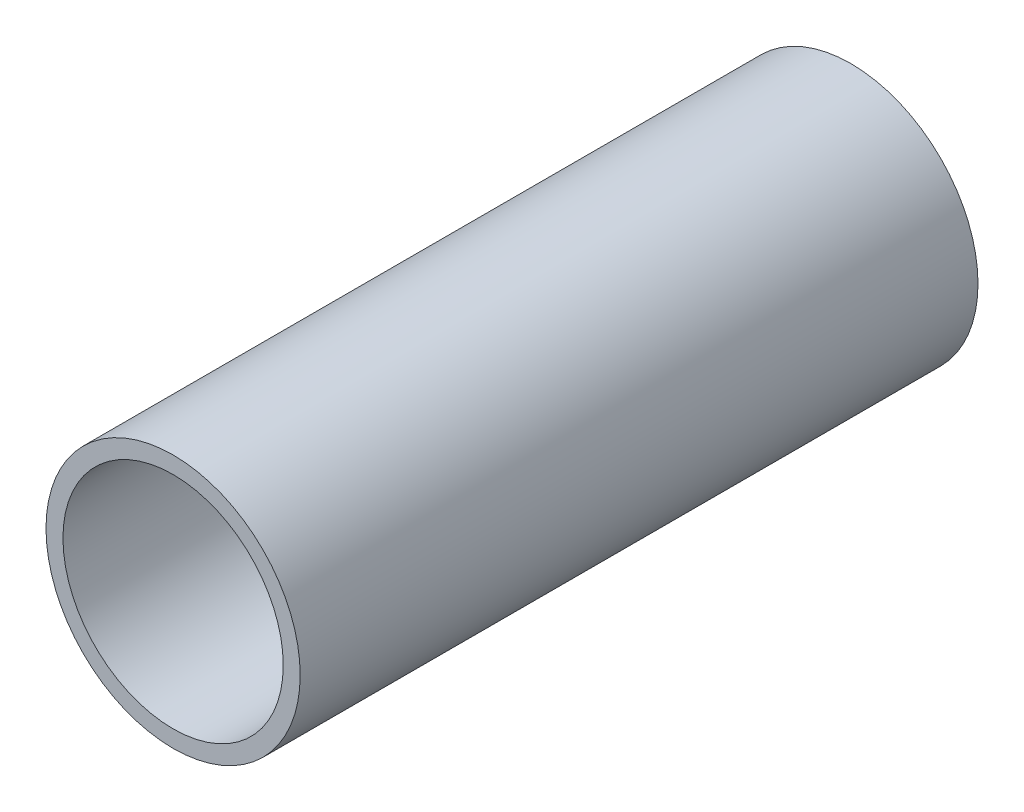
from build123d import *

# Parameters (mm, degrees)
SKETCH_1_R      = 15
SKETCH_1_R_2    = 13
EXTRUDE_1_DEPTH = 80


with BuildPart() as part:
    # 草图1 → 凸台-拉伸1 (new body)
    with BuildSketch(Plane.XY):
        Circle(SKETCH_1_R)
        Circle(SKETCH_1_R_2, mode=Mode.SUBTRACT)
    extrude(amount=-EXTRUDE_1_DEPTH)


solid = part.part
